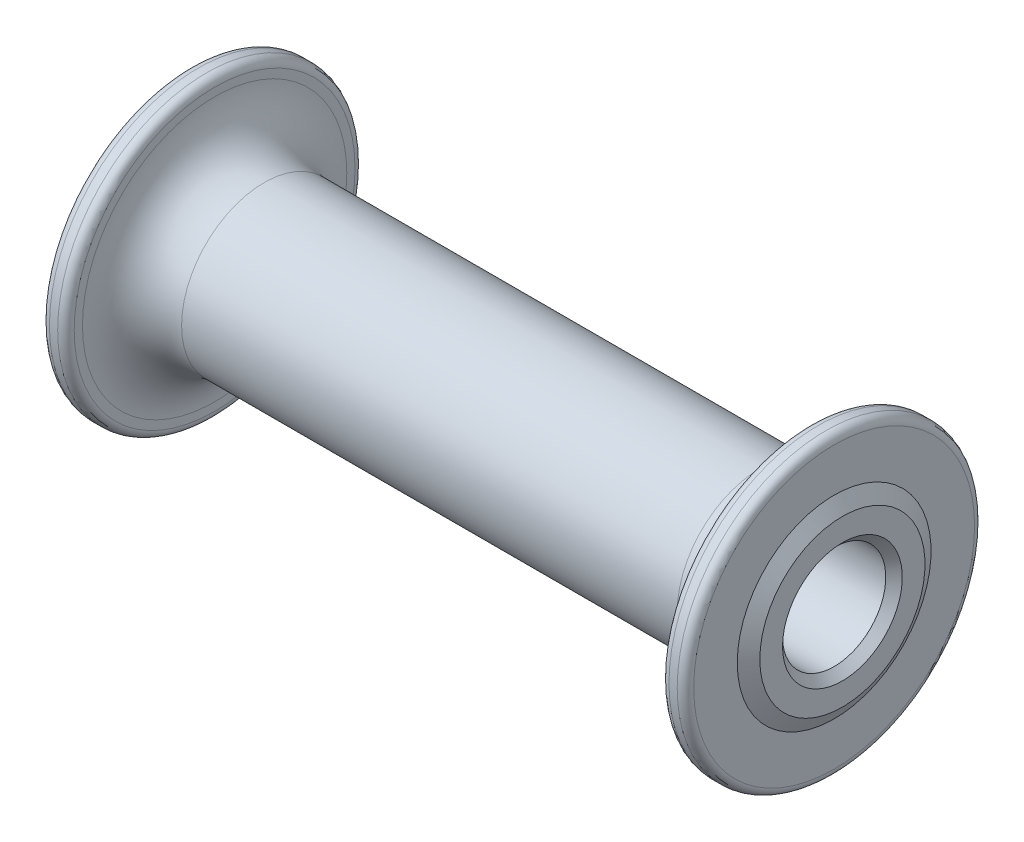
from build123d import *

# Parameters (mm, degrees)
KANTREIFNING1_SIZE = 1


with BuildPart() as part:
    # Sketch1 → Revolve1 (revolve)
    with BuildSketch(Plane.XY):
        with BuildLine():
            Line((40, 6.25), (40, 10))
            Line((40, 10), (39, 11.732050808))
            Line((39, 11.732050808), (39, 17))
            ThreePointArc((39, 17), (38.707106781, 17.707106781), (38, 18))
            Line((38, 18), (37, 18))
            ThreePointArc((37, 18), (36.292893219, 17.707106781), (36, 17))
            Line((36, 17), (36, 16))
            ThreePointArc((36, 16), (34.242640687, 11.757359313), (30, 10))
            Line((30, 10), (-30, 10))
            ThreePointArc((-30, 10), (-34.242640687, 11.757359313), (-36, 16))
            Line((-36, 16), (-36, 17))
            ThreePointArc((-36, 17), (-36.292893219, 17.707106781), (-37, 18))
            Line((-37, 18), (-38, 18))
            ThreePointArc((-38, 18), (-38.707106781, 17.707106781), (-39, 17))
            Line((-39, 17), (-39, 11.732050808))
            Line((-39, 11.732050808), (-40, 10))
            Line((-40, 10), (-40, 6.25))
            Line((-40, 6.25), (40, 6.25))
        make_face()
    revolve(axis=Axis((0, 0, 0), (1, 0, 0)))

    # Kantreifning1
    kantreifning1_edges = [part.edges().sort_by_distance(p)[0] for p in [
        (40, -6.25, 0),
        (-40, -6.25, 0),
    ]]
    chamfer(kantreifning1_edges, length=KANTREIFNING1_SIZE)


solid = part.part
